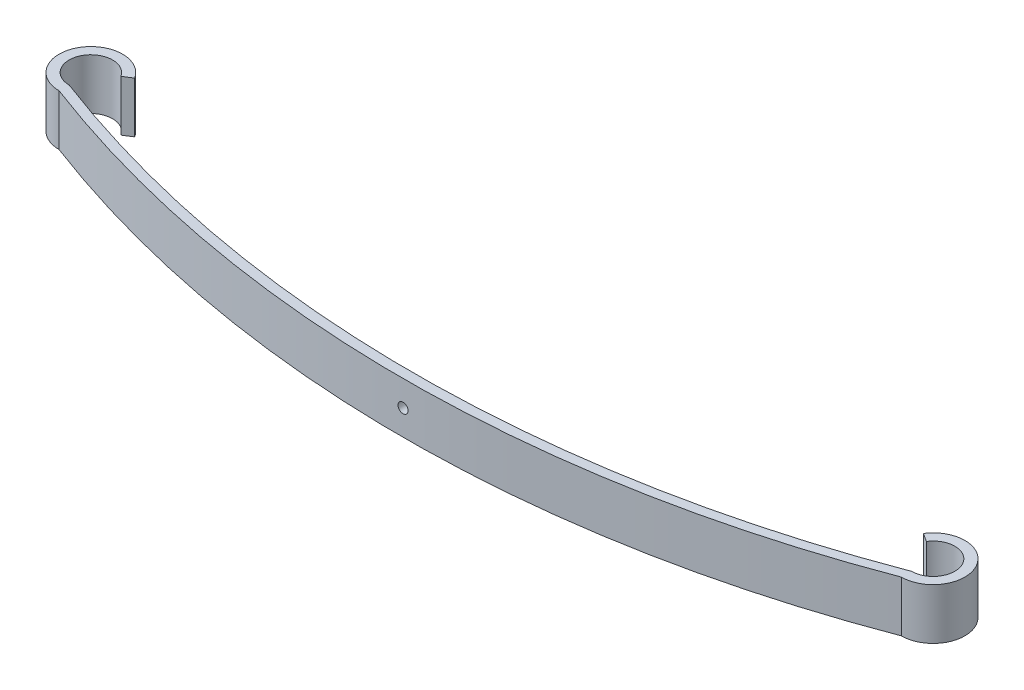
from build123d import *

# Parameters (mm, degrees)
BOSS_EXTRUDE1_DEPTH = 76.2
SKETCH6_R           = 7.5
CUT_EXTRUDE1_DEPTH  = 164


with BuildPart() as part:
    # Sketch1 → Boss-Extrude1 (new body)
    with BuildSketch(Plane(origin=(0, 0, 0), x_dir=(1, 0, 0), z_dir=(0, 1, 0))):
        with BuildLine():
            ThreePointArc((-630.001110861, -32.499999959), (-658.488874236, 15.640781416), (-602.579780619, 17.446534545))
            Line((-602.579780619, 17.446534545), (-589.924302497, 25.498776329))
            ThreePointArc((-589.924302497, 25.498776329), (-671.63274562, 22.868397775), (-630.021699517, -47.499985829))
            ThreePointArc((-630.021699517, -47.499985829), (0, -163), (630.021699517, -47.499985829))
            ThreePointArc((630.021699517, -47.499985829), (671.63274562, 22.868397775), (589.924302497, 25.498776329))
            Line((589.924302497, 25.498776329), (602.579780619, 17.446534545))
            ThreePointArc((602.579780619, 17.446534545), (658.488874236, 15.640781416), (630.001110861, -32.499999959))
            ThreePointArc((630.001110861, -32.499999959), (0, -148), (-630.001110861, -32.499999959))
        make_face()
    extrude(amount=BOSS_EXTRUDE1_DEPTH)

    # Sketch6 → Cut-Extrude1 (cut, through all)
    with BuildSketch(Plane.XY):
        with Locations((0, 38.1)):
            Circle(SKETCH6_R)
    extrude(amount=CUT_EXTRUDE1_DEPTH, mode=Mode.SUBTRACT)


solid = part.part
